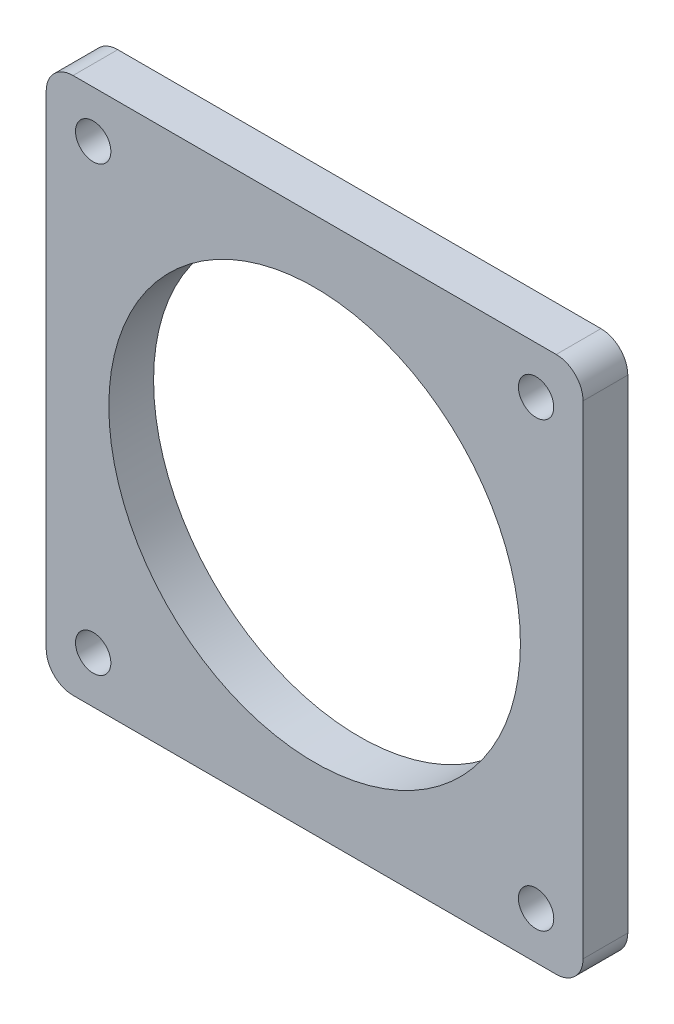
from build123d import *

# Parameters (mm, degrees)
SKETCH1_R           = 23
SKETCH1_R_2         = 1.975
BOSS_EXTRUDE1_DEPTH = 5


with BuildPart() as part:
    # Sketch1 → Boss-Extrude1 (new body)
    with BuildSketch(Plane.XY):
        with BuildLine():
            Line((-27, 30), (27, 30))
            ThreePointArc((27, 30), (29.121320344, 29.121320344), (30, 27))
            Line((30, 27), (30, -27))
            ThreePointArc((30, -27), (29.121320344, -29.121320344), (27, -30))
            Line((27, -30), (-27, -30))
            ThreePointArc((-27, -30), (-29.121320344, -29.121320344), (-30, -27))
            Line((-30, -27), (-30, 27))
            ThreePointArc((-30, 27), (-29.121320344, 29.121320344), (-27, 30))
        make_face()
        Circle(SKETCH1_R, mode=Mode.SUBTRACT)
        with Locations((-24.75, 24.75)):
            Circle(SKETCH1_R_2, mode=Mode.SUBTRACT)
        with Locations((24.75, 24.75)):
            Circle(SKETCH1_R_2, mode=Mode.SUBTRACT)
        with Locations((24.75, -24.75)):
            Circle(SKETCH1_R_2, mode=Mode.SUBTRACT)
        with Locations((-24.75, -24.75)):
            Circle(SKETCH1_R_2, mode=Mode.SUBTRACT)
    extrude(amount=BOSS_EXTRUDE1_DEPTH)


solid = part.part
